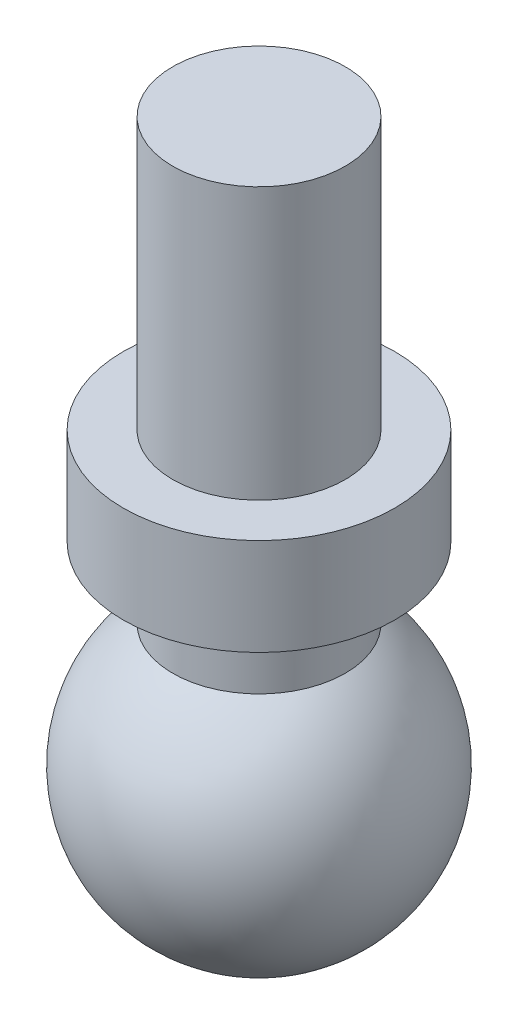
from build123d import *

# Parameters (mm, degrees)
SKETCH4_R      = 1.1303
EXTRUDE1_DEPTH = 7.366
SKETCH5_R      = 1.778
EXTRUDE2_DEPTH = 1.27


with BuildPart() as part:
    # Sketch3 → Revolve1 (revolve)
    with BuildSketch(Plane.XY):
        with BuildLine():
            Line((0, 1.9685), (0, -1.9685))
            ThreePointArc((0, -1.9685), (1.9685, 0), (0, 1.9685))
        make_face()
    revolve(axis=Axis((0, 1.9685, 0), (0, -1, 0)))

    # Sketch4 → Extrude1 (add)
    with BuildSketch(Plane(origin=(0, 0, 0), x_dir=(-1, 0, 0), z_dir=(0, 1, 0))):
        Circle(SKETCH4_R)
    extrude(amount=EXTRUDE1_DEPTH)

    # Sketch5 → Extrude2 (add)
    with BuildSketch(Plane(origin=(0, 2.54, 0), x_dir=(-1, 0, 0), z_dir=(0, 1, 0))):
        Circle(SKETCH5_R)
    extrude(amount=EXTRUDE2_DEPTH)


solid = part.part
